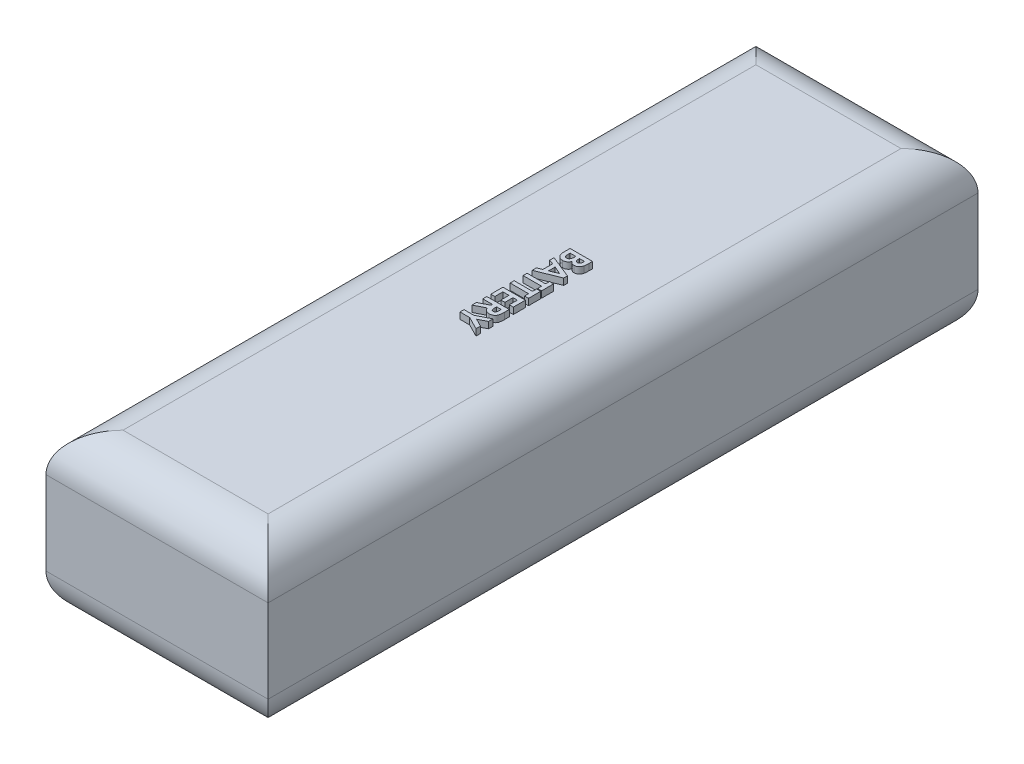
from build123d import *

# Parameters (mm, degrees)
SKETCH1_W           = 34.6
SKETCH1_H           = 110.6
BOSS_EXTRUDE1_DEPTH = 25
FILLET1_R           = 6
BOSS_EXTRUDE2_DEPTH = 1


with BuildPart() as part:
    # Sketch1 → Boss-Extrude1 (new body)
    with BuildSketch(Plane(origin=(0, 0, 0), x_dir=(1, 0, 0), z_dir=(0, 1, 0))):
        with Locations((-2.646431381, 9.8875)):
            Rectangle(SKETCH1_W, SKETCH1_H)
    extrude(amount=BOSS_EXTRUDE1_DEPTH)

    # Fillet1
    fillet1_edges = [part.edges().sort_by_distance(p)[0] for p in [
        (14.653568619, 25, -9.8875),
        (-2.646431381, 25, -65.1875),
        (-19.946431381, 25, -9.8875),
        (-2.646431381, 0, -65.1875),
        (14.653568619, 0, -9.8875),
        (-2.646431381, 0, 45.4125),
        (-19.946431381, 0, -9.8875),
        (-2.646431381, 25, 45.4125),
    ]]
    fillet(fillet1_edges, radius=FILLET1_R)

    # Sketch2 → Boss-Extrude2 (add)
    with BuildSketch(Plane(origin=(0, 25, 0), x_dir=(1, 0, 0), z_dir=(0, 1, 0))):
        with BuildLine():
            Line((-2.646431381, 18.929166667), (0.853568619, 18.929166667))
            Line((0.853568619, 18.929166667), (0.853568619, 18.368269231))
            add(Edge.make_bspline(
                [(0.853568619, 18.368269231), (0.853573979, 18.329002833), (0.853584351, 18.253023098), (0.849723102, 18.143405304), (0.844794522, 18.041972908), (0.839095406, 17.948602126), (0.829637046, 17.863327525), (0.819458063, 17.786090375), (0.80726394, 17.717176738), (0.796318362, 17.674571701), (0.791168779, 17.654527244)],
                knots=[0, 0, 0, 0, 0.000117791, 0.000227922, 0.000329003, 0.000422466, 0.000508487, 0.000586324, 0.000656183, 0.000718251, 0.000718251, 0.000718251, 0.000718251], degree=3))
            add(Edge.make_bspline(
                [(0.791168779, 17.654527244), (0.783905742, 17.628206785), (0.769653331, 17.576557596), (0.740869971, 17.502579477), (0.70887523, 17.432400899), (0.672375195, 17.366107611), (0.630929298, 17.304106448), (0.584208284, 17.246633893), (0.534088732, 17.192447202), (0.479169326, 17.143482198), (0.42114999, 17.099192134), (0.359985039, 17.060835054), (0.296909205, 17.027096867), (0.230169518, 17.001710013), (0.161730765, 16.980173228), (0.090279004, 16.965800505), (0.016461586, 16.956146956), (-0.033785756, 16.955258622), (-0.059291958, 16.954807692)],
                knots=[0, 0, 0, 0, 8.1863e-05, 0.000160642, 0.000237816, 0.000313134, 0.000387417, 0.000461218, 0.000535129, 0.000608609, 0.000681668, 0.000753832, 0.000825019, 0.000895846, 0.000967704, 0.001040031, 0.001114211, 0.001190685, 0.001190685, 0.001190685, 0.001190685], degree=3))
            add(Edge.make_bspline(
                [(-0.059291958, 16.954807692), (-0.09207675, 16.955905374), (-0.156648298, 16.958067322), (-0.251079708, 16.974562828), (-0.340926665, 17.001453362), (-0.427045246, 17.038529423), (-0.508448559, 17.089763891), (-0.587684141, 17.152521425), (-0.663369601, 17.229698209), (-0.709752953, 17.287867585), (-0.733771125, 17.317988782)],
                knots=[0, 0, 0, 0, 9.8317e-05, 0.000193641, 0.000286584, 0.000379201, 0.000473959, 0.000574259, 0.000681842, 0.000797376, 0.000797376, 0.000797376, 0.000797376], degree=3))
            add(Edge.make_bspline(
                [(-0.733771125, 17.317988782), (-0.746367065, 17.293310766), (-0.77106422, 17.244924003), (-0.811681957, 17.17625019), (-0.85479731, 17.112586167), (-0.900038186, 17.053878367), (-0.947734899, 17.000331825), (-0.998112901, 16.952294669), (-1.05030109, 16.908764961), (-1.105362863, 16.870780715), (-1.162637278, 16.837664199), (-1.222221648, 16.808585315), (-1.284962912, 16.785295406), (-1.34953094, 16.764399255), (-1.416885097, 16.749086396), (-1.486790356, 16.739029386), (-1.559057457, 16.731351592), (-1.608282123, 16.730753048), (-1.633310388, 16.730448718)],
                knots=[0, 0, 0, 0, 8.3106e-05, 0.000162948, 0.000239177, 0.000313644, 0.000385145, 0.000454073, 0.000522298, 0.000588812, 0.000654471, 0.000720637, 0.000787435, 0.000855067, 0.00092412, 0.000994323, 0.001066878, 0.001141928, 0.001141928, 0.001141928, 0.001141928], degree=3))
            add(Edge.make_bspline(
                [(-1.633310388, 16.730448718), (-1.681136675, 16.732323268), (-1.775569222, 16.736024549), (-1.913706925, 16.765901058), (-2.045454037, 16.813846713), (-2.168868546, 16.880431479), (-2.281210864, 16.961967233), (-2.379627784, 17.055822343), (-2.462661167, 17.160861798), (-2.519203607, 17.257414808), (-2.55696655, 17.341328488), (-2.5799973, 17.411145029), (-2.601774683, 17.485946127), (-2.616914929, 17.567089787), (-2.630811566, 17.653256142), (-2.639383149, 17.745303257), (-2.645194524, 17.843053882), (-2.64601076, 17.910193453), (-2.646431381, 17.944791667)],
                knots=[0, 0, 0, 0, 0.000143365, 0.000283073, 0.000421924, 0.000562767, 0.000702306, 0.000837188, 0.000969462, 0.001102698, 0.00117175, 0.001245141, 0.001323054, 0.001405279, 0.00149254, 0.001584838, 0.001682455, 0.001786243, 0.001786243, 0.001786243, 0.001786243], degree=3))
            Line((-2.646431381, 17.944791667), (-2.646431381, 18.929166667))
        make_face()
        with BuildLine():
            Line((0.22536349, 18.300961538), (-0.537457022, 18.300961538))
            Line((-0.537457022, 18.300961538), (-0.537457022, 18.134094551))
            add(Edge.make_bspline(
                [(-0.537457022, 18.134094551), (-0.537260157, 18.111415547), (-0.536880119, 18.067635102), (-0.53195089, 18.004403447), (-0.523603323, 17.945591782), (-0.511709365, 17.891277914), (-0.497296867, 17.841144569), (-0.478965548, 17.795785493), (-0.457093417, 17.755053394), (-0.425307935, 17.707060984), (-0.37663238, 17.657625928), (-0.307923318, 17.613359465), (-0.228395059, 17.587416171), (-0.172361491, 17.584512325), (-0.143426574, 17.583012821)],
                knots=[0, 0, 0, 0, 6.8023e-05, 0.000131315, 0.000190113, 0.000246084, 0.000297996, 0.000346429, 0.000392538, 0.000436486, 0.000518789, 0.000598535, 0.000679684, 0.000766331, 0.000766331, 0.000766331, 0.000766331], degree=3))
            add(Edge.make_bspline(
                [(-0.143426574, 17.583012821), (-0.116322843, 17.584212273), (-0.063918868, 17.586531368), (0.00971241, 17.612670709), (0.074621165, 17.653392062), (0.119701079, 17.700739521), (0.149976899, 17.745898494), (0.170266156, 17.784741846), (0.187884289, 17.82761083), (0.201821376, 17.874847569), (0.212090241, 17.926281389), (0.219673163, 17.981774291), (0.224822802, 18.041450321), (0.225179395, 18.082667473), (0.22536349, 18.103946314)],
                knots=[0, 0, 0, 0, 8.0997e-05, 0.000156604, 0.000231296, 0.000309146, 0.000350566, 0.000394159, 0.00044038, 0.000489404, 0.000541655, 0.000597578, 0.000657375, 0.000721192, 0.000721192, 0.000721192, 0.000721192], degree=3))
            Line((0.22536349, 18.103946314), (0.22536349, 18.300961538))
        make_face(mode=Mode.SUBTRACT)
        with BuildLine():
            Line((-1.120790356, 18.300961538), (-2.018226253, 18.300961538))
            Line((-2.018226253, 18.300961538), (-2.018226253, 18.120072115))
            add(Edge.make_bspline(
                [(-2.018226253, 18.120072115), (-2.018021946, 18.084310046), (-2.017629139, 18.015553005), (-2.012883104, 17.917058666), (-2.004329211, 17.827502689), (-1.993650364, 17.747122362), (-1.979182198, 17.675794568), (-1.960787778, 17.613760412), (-1.940550713, 17.560169177), (-1.915555534, 17.515342197), (-1.886467345, 17.478721123), (-1.856738516, 17.445674442), (-1.822443504, 17.418730239), (-1.785054498, 17.397411482), (-1.745500268, 17.378960135), (-1.702236235, 17.367831586), (-1.656544641, 17.359358699), (-1.624940754, 17.358892414), (-1.608771125, 17.358653846)],
                knots=[0, 0, 0, 0, 0.000107281, 0.000206261, 0.0002957, 0.000377105, 0.000449433, 0.000513769, 0.000571055, 0.000620973, 0.00066697, 0.000711118, 0.000754041, 0.00079709, 0.000840088, 0.000884486, 0.000930707, 0.00097913, 0.00097913, 0.00097913, 0.00097913], degree=3))
            add(Edge.make_bspline(
                [(-1.608771125, 17.358653846), (-1.590280842, 17.3591799), (-1.554266746, 17.360204512), (-1.501629256, 17.368574202), (-1.452485035, 17.383780406), (-1.405594583, 17.402947284), (-1.362573941, 17.429566102), (-1.322306194, 17.461292638), (-1.28506371, 17.49884611), (-1.250210804, 17.541952136), (-1.21915825, 17.592243614), (-1.192840429, 17.65006733), (-1.170308262, 17.715089151), (-1.152592897, 17.787706436), (-1.137504015, 17.867675561), (-1.128507143, 17.95561858), (-1.121811277, 18.050791465), (-1.121138395, 18.116786406), (-1.120790356, 18.150921474)],
                knots=[0, 0, 0, 0, 5.546e-05, 0.00010802, 0.00015926, 0.000209526, 0.000259547, 0.000310464, 0.000363015, 0.000417873, 0.000476437, 0.000539802, 0.000608096, 0.000682577, 0.000763849, 0.000852038, 0.000947599, 0.001049984, 0.001049984, 0.001049984, 0.001049984], degree=3))
            Line((-1.120790356, 18.150921474), (-1.120790356, 18.300961538))
        make_face(mode=Mode.SUBTRACT)
        Polygon((0.853568619, 15.024619391), (0.853568619, 14.441987179), (-2.646431381, 13.028525641), (-2.646431381, 13.699499199), (-1.928482663, 13.971534455), (-1.928482663, 15.496474359), (-2.646431381, 15.768509615), (-2.646431381, 16.438782051), align=None)
        Polygon((-0.085233465, 14.733653846), (-1.300277535, 15.258092949), (-1.300277535, 14.209214744), align=None, mode=Mode.SUBTRACT)
        Polygon((0.853568619, 12.871474359), (0.853568619, 10.986858974), (0.22536349, 10.986858974), (0.22536349, 11.615064103), (-2.646431381, 11.615064103), (-2.646431381, 12.243269231), (0.22536349, 12.243269231), (0.22536349, 12.871474359), align=None)
        Polygon((0.853568619, 10.85224359), (0.853568619, 8.967628205), (0.22536349, 8.967628205), (0.22536349, 9.595833333), (-2.646431381, 9.595833333), (-2.646431381, 10.224038462), (0.22536349, 10.224038462), (0.22536349, 10.85224359), align=None)
        Polygon((0.853568619, 8.474038462), (0.853568619, 6.589423077), (0.22536349, 6.589423077), (0.22536349, 7.845833333), (-0.447713433, 7.845833333), (-0.447713433, 6.589423077), (-1.075918561, 6.589423077), (-1.075918561, 7.845833333), (-2.018226253, 7.845833333), (-2.018226253, 6.589423077), (-2.646431381, 6.589423077), (-2.646431381, 8.474038462), align=None)
        with BuildLine():
            Line((0.853568619, 5.961217949), (0.853568619, 5.229246795))
            add(Edge.make_bspline(
                [(0.853568619, 5.229246795), (0.853397414, 5.180863647), (0.853068139, 5.087809225), (0.847850069, 4.95363107), (0.840621848, 4.830365599), (0.829456282, 4.71761921), (0.815017878, 4.615837987), (0.797501159, 4.524806358), (0.777712032, 4.444471462), (0.753457389, 4.37374832), (0.72552548, 4.310100265), (0.69399839, 4.250937455), (0.657684815, 4.195217016), (0.618056161, 4.141916211), (0.573693073, 4.091986432), (0.524955061, 4.045566022), (0.472193427, 4.002058094), (0.415725441, 3.961405071), (0.355629931, 3.925228525), (0.292760206, 3.893177889), (0.226946376, 3.866845282), (0.158565212, 3.844919481), (0.087534483, 3.82803795), (0.013900308, 3.816576013), (-0.062368616, 3.808100961), (-0.114188304, 3.807618105), (-0.140622086, 3.807371795)],
                knots=[0, 0, 0, 0, 0.000145139, 0.000279143, 0.000402781, 0.00051552, 0.000618938, 0.000711065, 0.000793539, 0.000866929, 0.000935057, 0.00100187, 0.001067798, 0.001134404, 0.001200955, 0.001267901, 0.001336126, 0.001405975, 0.001476437, 0.001546359, 0.001617446, 0.001688844, 0.001761629, 0.001836205, 0.001912318, 0.001991573, 0.001991573, 0.001991573, 0.001991573], degree=3))
            add(Edge.make_bspline(
                [(-0.140622086, 3.807371795), (-0.168212345, 3.808015757), (-0.222311814, 3.80927845), (-0.301779521, 3.816079998), (-0.377808664, 3.828511092), (-0.45017664, 3.847339793), (-0.519784152, 3.868980938), (-0.585346899, 3.897758111), (-0.647818395, 3.930235994), (-0.706314958, 3.968809027), (-0.762135912, 4.011141047), (-0.813142551, 4.060372295), (-0.862076287, 4.113313343), (-0.905872078, 4.172940201), (-0.947491237, 4.23662446), (-0.985209278, 4.305631461), (-1.019974347, 4.379510839), (-1.039361751, 4.4314517), (-1.049275933, 4.458012821)],
                knots=[0, 0, 0, 0, 8.278e-05, 0.000162316, 0.000239082, 0.000313563, 0.00038651, 0.000457489, 0.000528056, 0.000597481, 0.00066746, 0.000737887, 0.000809857, 0.000883475, 0.000959513, 0.001037964, 0.001119203, 0.001204224, 0.001204224, 0.001204224, 0.001204224], degree=3))
            Line((-1.049275933, 4.458012821), (-2.646431381, 3.650320513))
            Line((-2.646431381, 3.650320513), (-2.646431381, 4.348637821))
            Line((-2.646431381, 4.348637821), (-1.120790356, 5.119871795))
            Line((-1.120790356, 5.119871795), (-1.120790356, 5.333012821))
            Line((-1.120790356, 5.333012821), (-2.646431381, 5.333012821))
            Line((-2.646431381, 5.333012821), (-2.646431381, 5.961217949))
            Line((-2.646431381, 5.961217949), (0.853568619, 5.961217949))
        make_face()
        with BuildLine():
            Line((-0.492585228, 5.333012821), (-0.492585228, 5.088321314))
            add(Edge.make_bspline(
                [(-0.492585228, 5.088321314), (-0.492248303, 5.058405739), (-0.491603165, 5.00112384), (-0.488610642, 4.918745021), (-0.481400505, 4.843925143), (-0.472289813, 4.776344053), (-0.461773186, 4.715657989), (-0.446692089, 4.662420045), (-0.430561751, 4.615772457), (-0.410419843, 4.57638499), (-0.387916921, 4.542595916), (-0.36122513, 4.51427377), (-0.331985689, 4.489322978), (-0.298358253, 4.469751361), (-0.261720531, 4.453938756), (-0.221383219, 4.444132289), (-0.178076674, 4.436351786), (-0.147907844, 4.435842135), (-0.132208625, 4.435576923)],
                knots=[0, 0, 0, 0, 8.9755e-05, 0.000171861, 0.000247208, 0.00031513, 0.000376461, 0.000431743, 0.000480981, 0.000524253, 0.000564118, 0.000602321, 0.000640653, 0.00067901, 0.000718597, 0.000759921, 0.000803261, 0.000850283, 0.000850283, 0.000850283, 0.000850283], degree=3))
            add(Edge.make_bspline(
                [(-0.132208625, 4.435576923), (-0.113659472, 4.436289452), (-0.077223097, 4.437689084), (-0.024768214, 4.451578546), (0.023785157, 4.473685844), (0.068204055, 4.503995169), (0.107184889, 4.542142318), (0.14126705, 4.585845197), (0.168845441, 4.635748523), (0.18650801, 4.682284188), (0.197364567, 4.724916258), (0.205071319, 4.763265284), (0.211046832, 4.80779434), (0.216831568, 4.85825496), (0.220813348, 4.914864147), (0.223630661, 4.977517349), (0.22479966, 5.046249978), (0.225170135, 5.094163907), (0.22536349, 5.119170673)],
                knots=[0, 0, 0, 0, 5.5548e-05, 0.000109114, 0.000161511, 0.00021499, 0.000269533, 0.000324507, 0.000380689, 0.000439937, 0.000473268, 0.000512593, 0.000557212, 0.000608004, 0.00066495, 0.000727413, 0.000796137, 0.000871161, 0.000871161, 0.000871161, 0.000871161], degree=3))
            Line((0.22536349, 5.119170673), (0.22536349, 5.333012821))
            Line((0.22536349, 5.333012821), (-0.492585228, 5.333012821))
        make_face(mode=Mode.SUBTRACT)
        Polygon((0.853568619, 3.425961538), (0.853568619, 2.726943109), (-0.374095644, 2.10224359), (0.853568619, 1.477544071), (0.853568619, 0.778525641), (-1.130606061, 1.788141026), (-2.646431381, 1.788141026), (-2.646431381, 2.416346154), (-1.130606061, 2.416346154), align=None)
    extrude(amount=BOSS_EXTRUDE2_DEPTH)


solid = part.part
